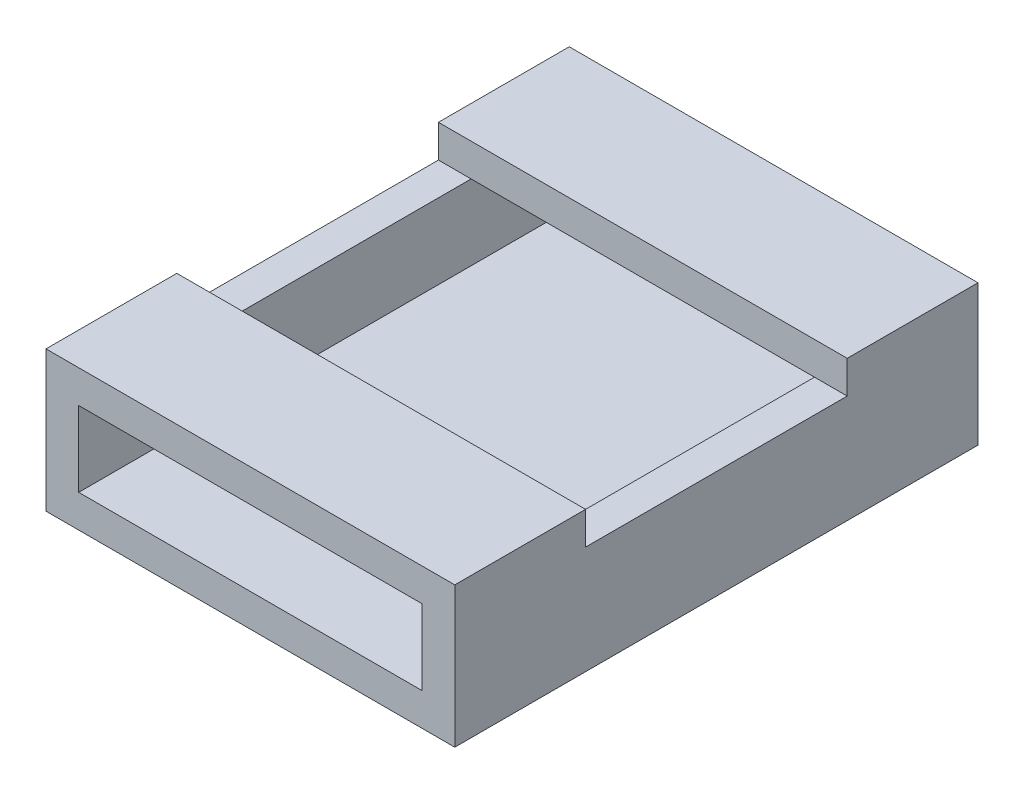
from build123d import *

# Parameters (mm, degrees)
SKETCH_2_W           = 10.5
SKETCH_2_H           = 4
EXTRUDE_1_DEPTH      = 1
SKETCH_3_W           = 1
SKETCH_3_H           = 16
EXTRUDE_2_DEPTH      = 2.3
EXTRUDE_2_DEPTH_BACK = 1
SKETCH_4_W           = 12.5
SKETCH_4_H           = 4
EXTRUDE_3_DEPTH      = 1


with BuildPart() as part:
    # 草图2 → 凸台-拉伸1 (new body)
    with BuildSketch(Plane(origin=(0, 0, 0), x_dir=(1, 0, 0), z_dir=(0, 1, 0))):
        with Locations((5.25, 6)):
            Rectangle(SKETCH_2_W, SKETCH_2_H)
        with Locations((5.25, 2)):
            Rectangle(SKETCH_2_W, SKETCH_2_H)
        with Locations((5.25, -2)):
            Rectangle(SKETCH_2_W, SKETCH_2_H)
        with Locations((5.25, -6)):
            Rectangle(SKETCH_2_W, SKETCH_2_H)
    extrude(amount=EXTRUDE_1_DEPTH)

    # 草图3 → 凸台-拉伸2 (add, two sides)
    with BuildSketch(Plane(origin=(0, 1, 0), x_dir=(1, 0, 0), z_dir=(0, 1, 0))) as extrude_2_sk:
        with Locations((11, 0)):
            Rectangle(SKETCH_3_W, SKETCH_3_H)
        with Locations((-0.5, 0)):
            Rectangle(SKETCH_3_W, SKETCH_3_H)
    extrude(amount=EXTRUDE_2_DEPTH)
    extrude(extrude_2_sk.sketch, amount=-EXTRUDE_2_DEPTH_BACK)

    # 草图4 → 凸台-拉伸3 (add)
    with BuildSketch(Plane(origin=(0, 3.3, 0), x_dir=(1, 0, 0), z_dir=(0, 1, 0))):
        with Locations((5.25, 6)):
            Rectangle(SKETCH_4_W, SKETCH_4_H)
        with Locations((5.25, -6)):
            Rectangle(SKETCH_4_W, SKETCH_4_H)
    extrude(amount=EXTRUDE_3_DEPTH)


solid = part.part
